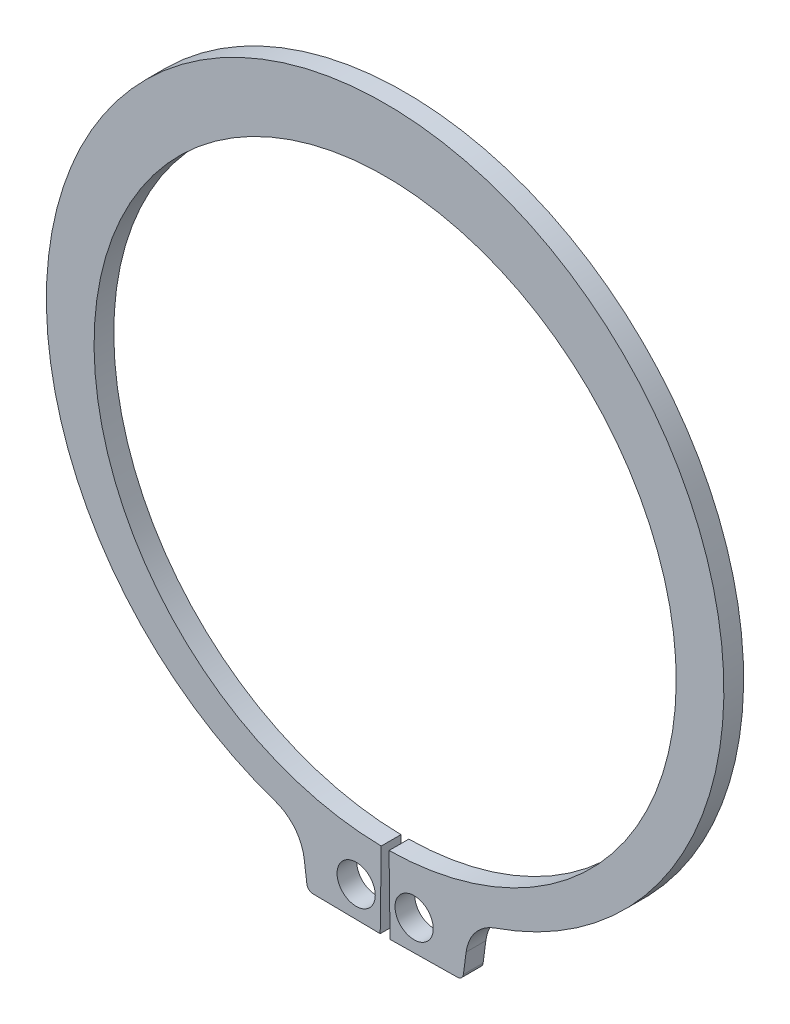
from build123d import *

# Parameters (mm, degrees)
BODYSKE_R  = 1.55
BODY_DEPTH = 1.6


with BuildPart() as part:
    # BodySke → Body (new body)
    with BuildSketch(Plane.XY):
        with BuildLine():
            Line((0.316778523, -23.597873874), (0.4, -29.797315315))
            Line((0.4, -29.797315315), (5.855032724, -29.724086802))
            ThreePointArc((5.855032724, -29.724086802), (6.180509806, -29.597830665), (6.344043745, -29.289394944))
            Line((6.344043745, -29.289394944), (6.56613254, -27.602463064))
            ThreePointArc((6.56613254, -27.602463064), (7.327456488, -25.842913161), (8.901599048, -24.748515967))
            ThreePointArc((8.901599048, -24.748515967), (0, 28.7), (-8.901599048, -24.748515967))
            ThreePointArc((-8.901599048, -24.748515967), (-7.327456488, -25.842913161), (-6.56613254, -27.602463064))
            Line((-6.56613254, -27.602463064), (-6.344043745, -29.289394944))
            ThreePointArc((-6.344043745, -29.289394944), (-6.180509806, -29.597830665), (-5.855032724, -29.724086802))
            Line((-5.855032724, -29.724086802), (-0.4, -29.797315315))
            Line((-0.4, -29.797315315), (-0.316778523, -23.597873874))
            ThreePointArc((-0.316778523, -23.597873874), (0, 23.6), (0.316778523, -23.597873874))
        make_face()
        with Locations((2.35, -27.299038445)):
            Circle(BODYSKE_R, mode=Mode.SUBTRACT)
        with Locations((-2.35, -27.299038445)):
            Circle(BODYSKE_R, mode=Mode.SUBTRACT)
    extrude(amount=-BODY_DEPTH)


solid = part.part
